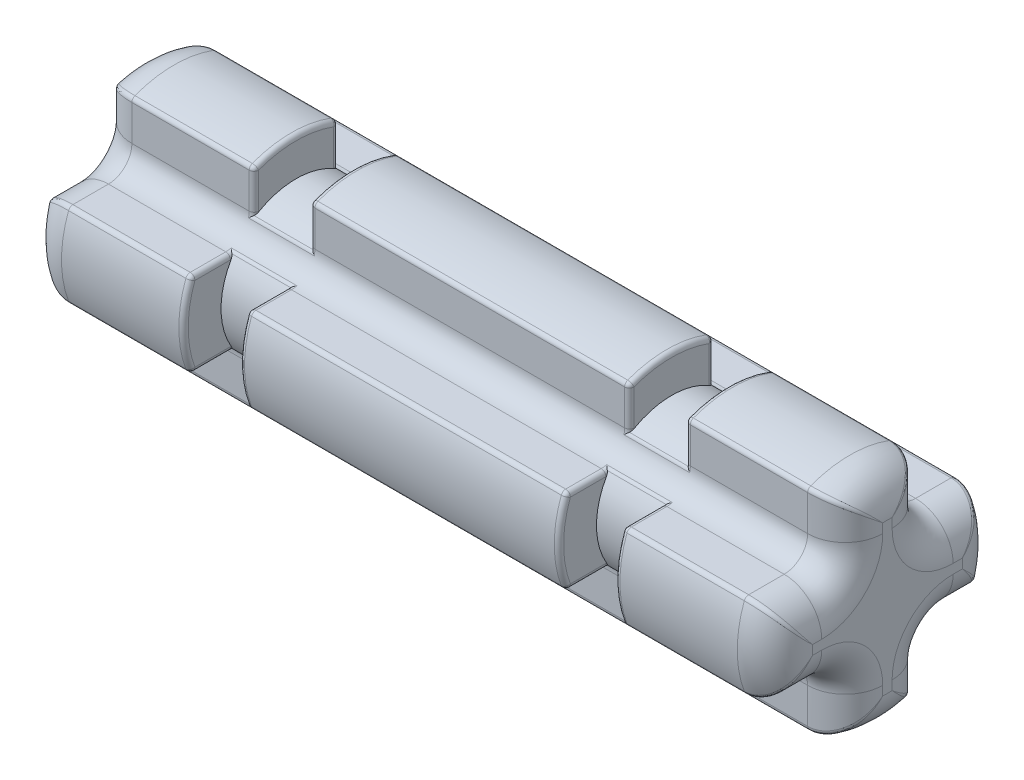
from build123d import *

# Parameters (mm, degrees)
SALIENTE_EXTRUIR1_DEPTH = 16
CROQUIS2_W              = 1.2
CROQUIS2_H              = 1.4
REDONDEO2_R             = 0.8
REDONDEO1_R             = 0.1


with BuildPart() as part:
    # Croquis1 → Saliente-Extruir1 (new body)
    with BuildSketch(Plane(origin=(0, 0, 0), x_dir=(0, 0, -1), z_dir=(1, 0, 0))):
        with BuildLine():
            Line((-1.4, 0.9), (-2.224859546, 0.9))
            ThreePointArc((-2.224859546, 0.9), (-2.4, 0), (-2.224859546, -0.9))
            Line((-2.224859546, -0.9), (-1.4, -0.9))
            ThreePointArc((-1.4, -0.9), (-1.046446609, -1.046446609), (-0.9, -1.4))
            Line((-0.9, -1.4), (-0.9, -2.224859546))
            ThreePointArc((-0.9, -2.224859546), (0, -2.4), (0.9, -2.224859546))
            Line((0.9, -2.224859546), (0.9, -1.4))
            ThreePointArc((0.9, -1.4), (1.046446609, -1.046446609), (1.4, -0.9))
            Line((1.4, -0.9), (2.224859546, -0.9))
            ThreePointArc((2.224859546, -0.9), (2.4, 0), (2.224859546, 0.9))
            Line((2.224859546, 0.9), (1.4, 0.9))
            ThreePointArc((1.4, 0.9), (1.046446609, 1.046446609), (0.9, 1.4))
            Line((0.9, 1.4), (0.9, 2.224859546))
            ThreePointArc((0.9, 2.224859546), (0, 2.4), (-0.9, 2.224859546))
            Line((-0.9, 2.224859546), (-0.9, 1.4))
            ThreePointArc((-0.9, 1.4), (-1.046446609, 1.046446609), (-1.4, 0.9))
        make_face()
    extrude(amount=SALIENTE_EXTRUIR1_DEPTH)

    # Croquis2 → Cortar-Revolución1 (revolve, cut)
    with BuildSketch(Plane.XY):
        with Locations((4, 2.3)):
            Rectangle(CROQUIS2_W, CROQUIS2_H)
        with Locations((12, 2.3)):
            Rectangle(CROQUIS2_W, CROQUIS2_H)
    revolve(axis=Axis((0, 0, 0), (1, 0, 0)), mode=Mode.SUBTRACT)

    # Redondeo2
    redondeo2_edges = [part.edges().sort_by_distance(p)[0] for p in [
        (16, 1.046446609, 1.046446609),
        (16, 0.9, 1.812429773),
        (0, 1.812429773, -0.9),
        (0, 1.046446609, -1.046446609),
        (0, 0.9, -1.812429773),
        (0, 0, -2.4),
        (0, -0.9, -1.812429773),
        (16, 0, 2.4),
        (0, -1.046446609, -1.046446609),
        (0, -1.812429773, -0.9),
        (0, -2.4, 0),
        (0, -1.812429773, 0.9),
        (0, -1.046446609, 1.046446609),
        (0, -0.9, 1.812429773),
        (0, 0, 2.4),
        (0, 0.9, 1.812429773),
        (16, -0.9, 1.812429773),
        (0, 1.046446609, 1.046446609),
        (0, 1.812429773, 0.9),
        (0, 2.4, 0),
        (16, -1.046446609, 1.046446609),
        (16, -1.812429773, 0.9),
        (16, -2.4, 0),
        (16, -1.812429773, -0.9),
        (16, -1.046446609, -1.046446609),
        (16, -0.9, -1.812429773),
        (16, 2.4, 0),
        (16, 0, -2.4),
        (16, 0.9, -1.812429773),
        (16, 1.046446609, -1.046446609),
        (16, 1.812429773, -0.9),
        (16, 1.812429773, 0.9),
    ]]
    fillet(redondeo2_edges, radius=REDONDEO2_R)

    # Redondeo1
    redondeo1_edges = [part.edges().sort_by_distance(p)[0] for p in [
        (8, 2.224859546, -0.9),
        (12.6, 1.812429773, -0.9),
        (11.4, 1.812429773, -0.9),
        (12, 1.31827597, -0.90672403),
        (12, 0.90672403, -1.31827597),
        (8, 0.9, -2.224859546),
        (8, -0.9, -2.224859546),
        (8, -2.224859546, -0.9),
        (8, -2.224859546, 0.9),
        (8, -0.9, 2.224859546),
        (8, 0.9, 2.224859546),
        (8, 2.224859546, 0.9),
        (12, 0.90672403, 1.31827597),
        (12, 1.31827597, 0.90672403),
        (12, -1.31827597, 0.90672403),
        (12, -0.90672403, 1.31827597),
        (12, -0.90672403, -1.31827597),
        (12, -1.31827597, -0.90672403),
        (11.4, 0.901683843, 1.35899991),
        (11.4, 0.9, 1.812429773),
        (11.4, 0, 2.4),
        (11.4, -0.9, 1.812429773),
        (11.4, -0.901683843, 1.35899991),
        (11.4, -1.35899991, 0.901683843),
        (11.4, -1.812429773, 0.9),
        (11.4, -2.4, 0),
        (11.4, -1.812429773, -0.9),
        (11.4, -1.35899991, -0.901683843),
        (11.4, -0.901683843, -1.35899991),
        (11.4, -0.9, -1.812429773),
        (11.4, 0, -2.4),
        (11.4, 0.9, -1.812429773),
        (11.4, 0.901683843, -1.35899991),
        (11.4, 1.35899991, -0.901683843),
        (11.4, 2.4, 0),
        (11.4, 1.812429773, 0.9),
        (11.4, 1.35899991, 0.901683843),
        (12.6, 0.9, 1.812429773),
        (12.6, 0.901683843, 1.35899991),
        (12.6, 1.35899991, 0.901683843),
        (12.6, 1.812429773, 0.9),
        (12.6, 2.4, 0),
        (12.6, 1.35899991, -0.901683843),
        (12.6, 0.901683843, -1.35899991),
        (12.6, 0.9, -1.812429773),
        (12.6, 0, -2.4),
        (12.6, -0.9, -1.812429773),
        (12.6, -0.901683843, -1.35899991),
        (12.6, -1.35899991, -0.901683843),
        (12.6, -1.812429773, -0.9),
        (12.6, -2.4, 0),
        (12.6, -1.812429773, 0.9),
        (12.6, -1.35899991, 0.901683843),
        (12.6, -0.901683843, 1.35899991),
        (12.6, -0.9, 1.812429773),
        (12.6, 0, 2.4),
        (13.9, 2.224859546, -0.9),
        (13.9, 0.9, -2.224859546),
        (13.9, -0.9, -2.224859546),
        (13.9, -2.224859546, -0.9),
        (13.9, -2.224859546, 0.9),
        (13.9, -0.9, 2.224859546),
        (13.9, 0.9, 2.224859546),
        (13.9, 2.224859546, 0.9),
        (0.195901206, -2.030615221, -0.624466058),
        (0.195901205, -2.030615221, 0.624466058),
        (0.195901208, -0.624466061, -2.030615223),
        (0.195901211, 0.624466065, -2.030615226),
        (0.195901205, -0.624466058, 2.030615221),
        (0.195901207, 0.62446606, 2.030615222),
        (0.195901205, 2.030615221, -0.624466058),
        (0.195901211, 2.030615226, 0.624466065),
        (15.804098792, -2.030615223, 0.624466061),
        (15.804098792, -2.030615223, -0.624466061),
        (15.804098792, -0.624466061, 2.030615223),
        (15.804098792, 0.624466061, 2.030615223),
        (15.804098792, -0.624466061, -2.030615223),
        (15.804098792, 0.624466061, -2.030615223),
        (15.804098792, 2.030615223, 0.624466061),
        (15.804098792, 2.030615224, -0.624466061),
        (2.1, 2.224859546, -0.9),
        (4.6, 1.812429773, -0.9),
        (3.4, 1.812429773, -0.9),
        (4, 0.90672403, -1.31827597),
        (4, 1.31827597, -0.90672403),
        (2.1, 0.9, -2.224859546),
        (2.1, -0.9, -2.224859546),
        (2.1, -2.224859546, -0.9),
        (2.1, -2.224859546, 0.9),
        (2.1, -0.9, 2.224859546),
        (2.1, 0.9, 2.224859546),
        (2.1, 2.224859546, 0.9),
        (4, 0.90672403, 1.31827597),
        (4, 1.31827597, 0.90672403),
        (4, -1.31827597, 0.90672403),
        (4, -0.90672403, 1.31827597),
        (4, -0.90672403, -1.31827597),
        (4, -1.31827597, -0.90672403),
        (3.4, 0.901683843, 1.35899991),
        (3.4, 0.9, 1.812429773),
        (3.4, 0, 2.4),
        (3.4, -0.9, 1.812429773),
        (3.4, -0.901683843, 1.35899991),
        (3.4, -1.35899991, 0.901683843),
        (3.4, -1.812429773, 0.9),
        (3.4, -2.4, 0),
        (3.4, -1.812429773, -0.9),
        (3.4, -1.35899991, -0.901683843),
        (3.4, -0.901683843, -1.35899991),
        (3.4, -0.9, -1.812429773),
        (3.4, 0, -2.4),
        (3.4, 0.9, -1.812429773),
        (3.4, 0.901683843, -1.35899991),
        (3.4, 1.35899991, -0.901683843),
        (3.4, 2.4, 0),
        (3.4, 1.812429773, 0.9),
        (3.4, 1.35899991, 0.901683843),
        (4.6, 0.9, 1.812429773),
        (4.6, 0.901683843, 1.35899991),
        (4.6, 1.35899991, 0.901683843),
        (4.6, 1.812429773, 0.9),
        (4.6, 2.4, 0),
        (4.6, 1.35899991, -0.901683843),
        (4.6, 0.901683843, -1.35899991),
        (4.6, 0.9, -1.812429773),
        (4.6, 0, -2.4),
        (4.6, -0.9, -1.812429773),
        (4.6, -0.901683843, -1.35899991),
        (4.6, -1.35899991, -0.901683843),
        (4.6, -1.812429773, -0.9),
        (4.6, -2.4, 0),
        (4.6, -1.812429773, 0.9),
        (4.6, -1.35899991, 0.901683843),
        (4.6, -0.901683843, 1.35899991),
        (4.6, -0.9, 1.812429773),
        (4.6, 0, 2.4),
    ]]
    fillet(redondeo1_edges, radius=REDONDEO1_R)


solid = part.part
